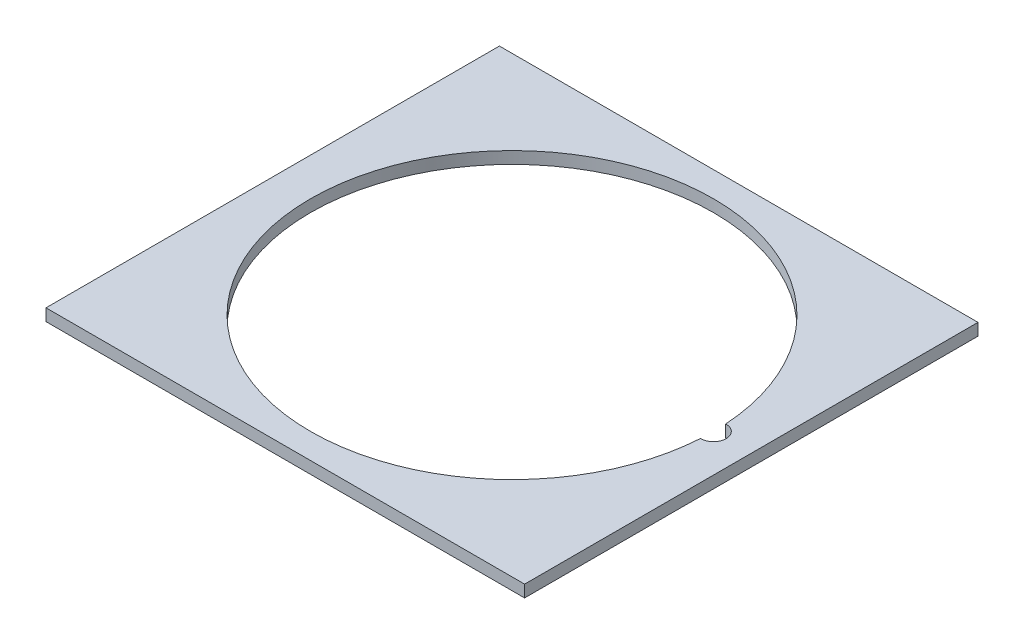
from build123d import *

# Parameters (mm, degrees)
SKETCH1_W           = 190
SKETCH1_H           = 180
BOSS_EXTRUDE1_DEPTH = 4.7625


with BuildPart() as part:
    # Sketch1 → Boss-Extrude1 (new body)
    with BuildSketch(Plane(origin=(0, 0, 0), x_dir=(1, 0, 0), z_dir=(0, 1, 0))):
        Rectangle(SKETCH1_W, SKETCH1_H)
        with BuildLine():
            ThreePointArc((79.84375, 4.997557997), (-80, 0), (79.84375, -4.997557997))
            ThreePointArc((79.84375, -4.997557997), (85, 0), (79.84375, 4.997557997))
        make_face(mode=Mode.SUBTRACT)
    extrude(amount=BOSS_EXTRUDE1_DEPTH)


solid = part.part
